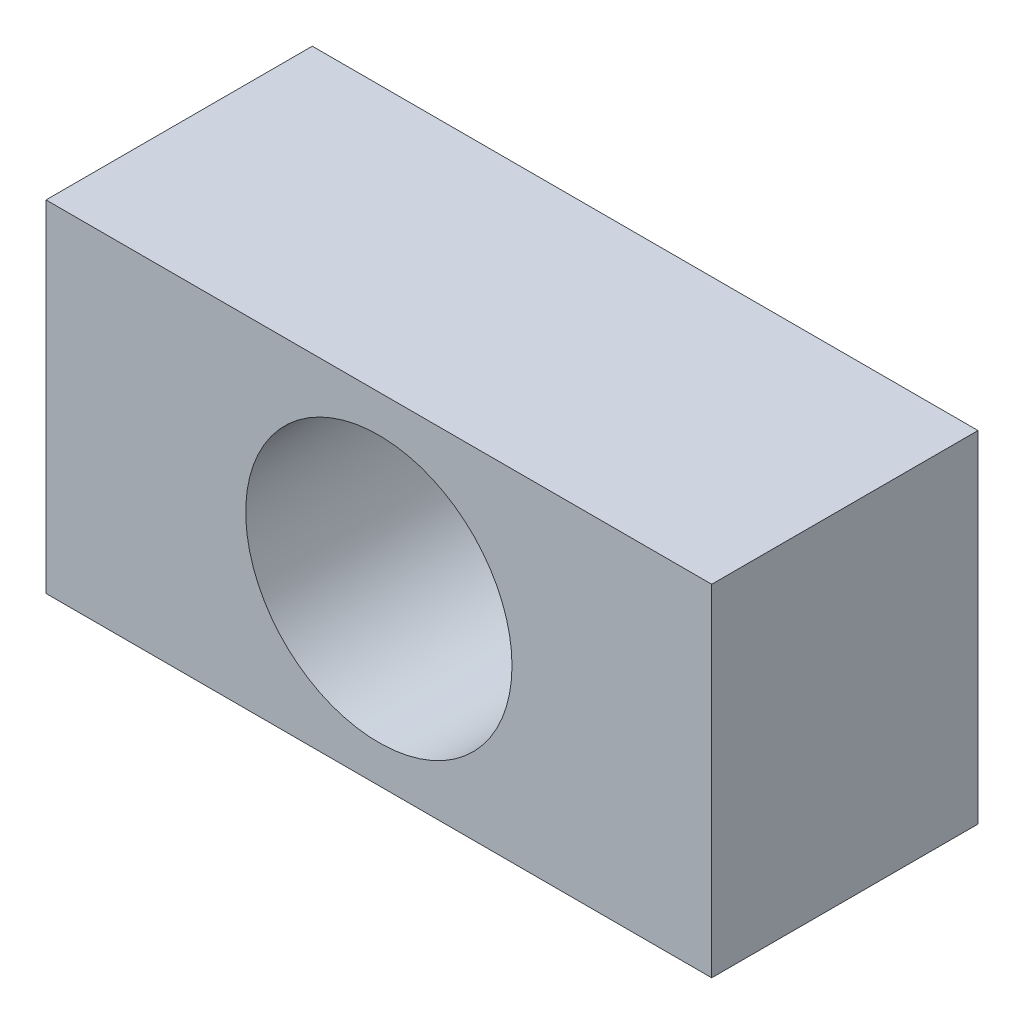
from build123d import *

# Parameters (mm, degrees)
SKETCH_1_W      = 7.5
SKETCH_1_H      = 3.84
SKETCH_1_R      = 1.5
EXTRUDE_1_DEPTH = 3


with BuildPart() as part:
    # 草图1 → 凸台-拉伸1 (new body)
    with BuildSketch(Plane.XY):
        with Locations((1.090909091, -1.864090909)):
            Rectangle(SKETCH_1_W, SKETCH_1_H)
        with Locations((1.090909091, -1.864090909)):
            Circle(SKETCH_1_R, mode=Mode.SUBTRACT)
    extrude(amount=EXTRUDE_1_DEPTH)


solid = part.part
